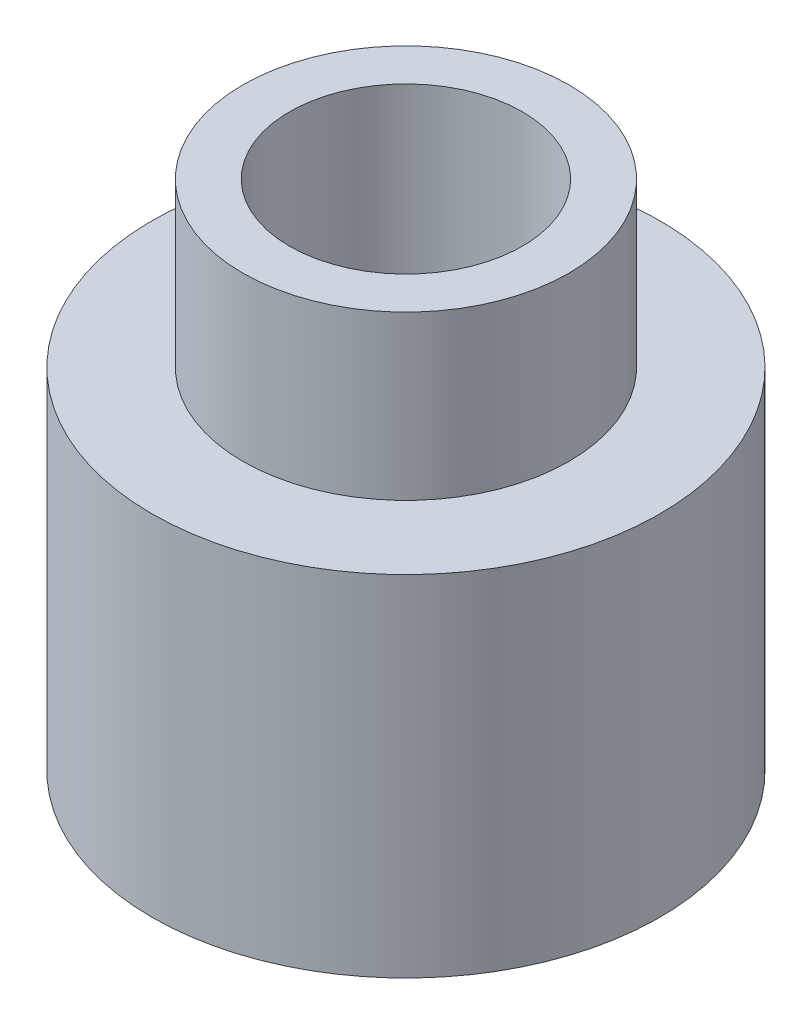
from build123d import *

# Parameters (mm, degrees)
SKETCH_1_R          = 2.18
EXTRUDE_1_DEPTH     = 3
SKETCH_2_R          = 1.4
EXTRUDE_2_DEPTH     = 1.4
SKETCH_3_R          = 1
CUT_EXTRUDE_1_DEPTH = 10


with BuildPart() as part:
    # Эскиз1 → Бобышка-Вытянуть1 (new body)
    with BuildSketch(Plane(origin=(0, 0, 0), x_dir=(1, 0, 0), z_dir=(0, 1, 0))):
        Circle(SKETCH_1_R)
    extrude(amount=EXTRUDE_1_DEPTH)

    # Эскиз2 → Бобышка-Вытянуть2 (add)
    with BuildSketch(Plane(origin=(0, 3, 0), x_dir=(1, 0, 0), z_dir=(0, 1, 0))):
        Circle(SKETCH_2_R)
    extrude(amount=EXTRUDE_2_DEPTH)

    # Эскиз3 → Вырез-Вытянуть1 (cut)
    with BuildSketch(Plane(origin=(0, 4.4, 0), x_dir=(1, 0, 0), z_dir=(0, 1, 0))):
        Circle(SKETCH_3_R)
    extrude(amount=-CUT_EXTRUDE_1_DEPTH, mode=Mode.SUBTRACT)


solid = part.part
